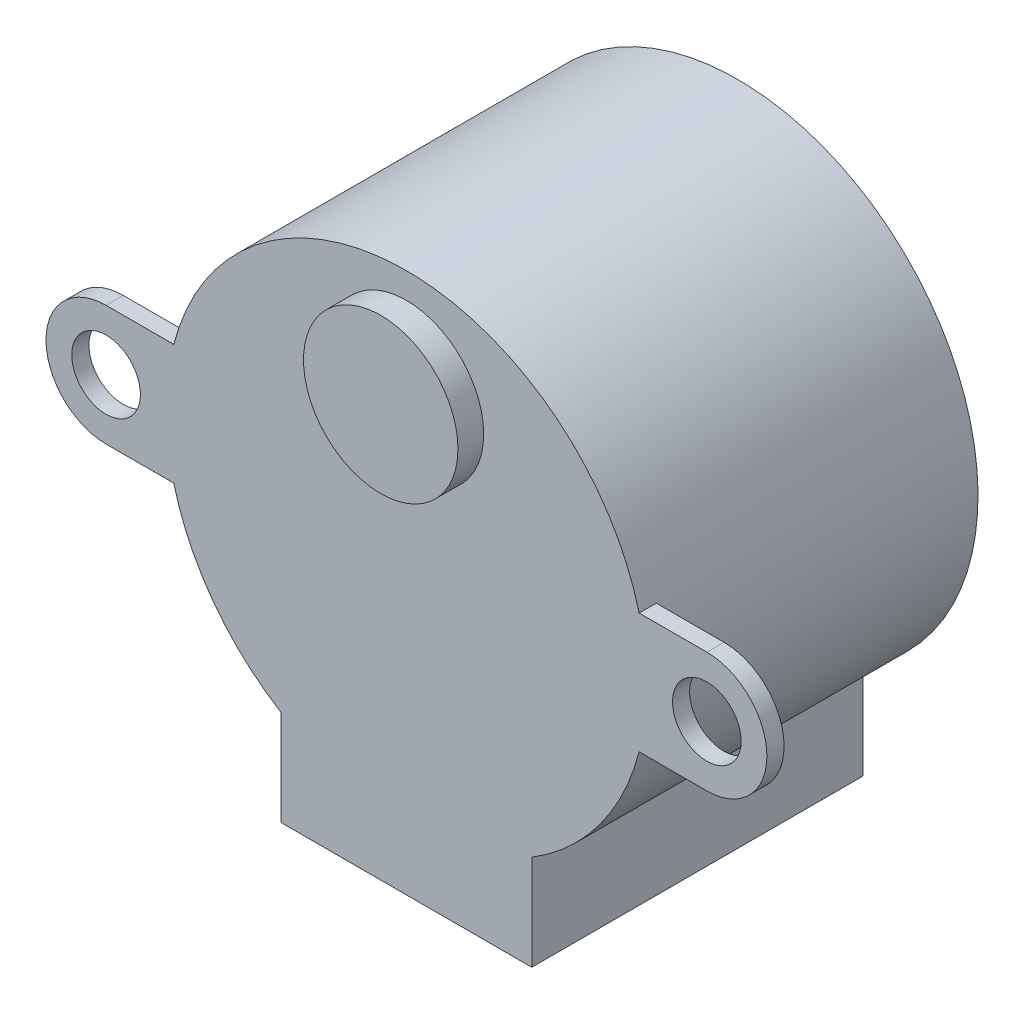
from build123d import *

# Parameters (mm, degrees)
SKETCH_1_R      = 14
EXTRUDE_1_DEPTH = 19.3
SKETCH_3_R      = 2
EXTRUDE_2_DEPTH = 1
SKETCH_4_R      = 4.5
EXTRUDE_3_DEPTH = 1.5
SKETCH_6_W      = 14.6
SKETCH_6_H      = 5.55387092
EXTRUDE_4_DEPTH = 19.3


with BuildPart() as part:
    # 草图1 → 凸台-拉伸1 (new body)
    with BuildSketch(Plane.XY):
        with Locations((-50.023496645, 38.50258845)):
            Circle(SKETCH_1_R)
    extrude(amount=EXTRUDE_1_DEPTH)

    # 草图3 → 凸台-拉伸2 (add)
    with BuildSketch(Plane.XY.offset(19.3)):
        with BuildLine():
            Line((-63.578938357, 42.00258845), (-67.523496645, 42.00258845))
            ThreePointArc((-67.523496645, 42.00258845), (-71.023496645, 38.50258845), (-67.523496645, 35.00258845))
            Line((-67.523496645, 35.00258845), (-63.578938357, 35.00258845))
            ThreePointArc((-63.578938357, 35.00258845), (-64.023496645, 38.50258845), (-63.578938357, 42.00258845))
        make_face()
        with Locations((-67.523496645, 38.50258845)):
            Circle(SKETCH_3_R, mode=Mode.SUBTRACT)
        with BuildLine():
            Line((-32.523496645, 42.00258845), (-36.468054934, 42.00258845))
            ThreePointArc((-36.468054934, 42.00258845), (-36.135080898, 40.266648545), (-36.023496645, 38.50258845))
            ThreePointArc((-36.023496645, 38.50258845), (-36.135080898, 36.738528355), (-36.468054934, 35.00258845))
            Line((-36.468054934, 35.00258845), (-32.523496645, 35.00258845))
            ThreePointArc((-32.523496645, 35.00258845), (-29.023496645, 38.50258845), (-32.523496645, 42.00258845))
        make_face()
        with Locations((-32.523496645, 38.50258845)):
            Circle(SKETCH_3_R, mode=Mode.SUBTRACT)
        with BuildLine():
            ThreePointArc((-42.723496645, 26.55645937), (-50.023496645, 24.50258845), (-57.323496645, 26.55645937))
            Line((-57.323496645, 26.55645937), (-57.323496645, 21.00258845))
            Line((-57.323496645, 21.00258845), (-42.723496645, 21.00258845))
            Line((-42.723496645, 21.00258845), (-42.723496645, 26.55645937))
        make_face()
    extrude(amount=-EXTRUDE_2_DEPTH)

    # 草图4 → 凸台-拉伸3 (add)
    with BuildSketch(Plane.XY.offset(19.3)):
        with Locations((-50.023496645, 46.50258845)):
            Circle(SKETCH_4_R)
    extrude(amount=EXTRUDE_3_DEPTH)

    # 草图6 → 凸台-拉伸4 (add)
    with BuildSketch(Plane.XY.offset(19.3)):
        with Locations((-50.023496645, 23.77952391)):
            Rectangle(SKETCH_6_W, SKETCH_6_H)
    extrude(amount=-EXTRUDE_4_DEPTH)


solid = part.part
